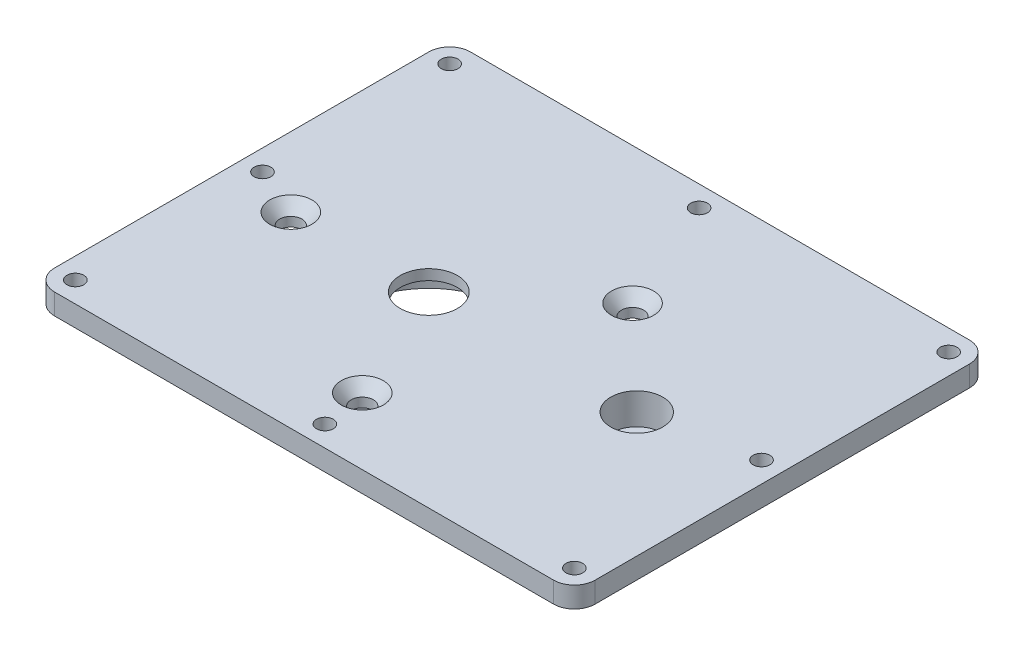
from build123d import *

# Parameters (mm, degrees)
SKETCH1_W                                        = 165.1
SKETCH1_H                                        = 127
SKETCH1_R                                        = 7.14375
SKETCH1_R_2                                      = 7.9375
BOSS_EXTRUDE1_DEPTH                              = 6.35
SKETCH2_R                                        = 28.575
SKETCH2_R_2                                      = 7.14375
SKETCH2_R_3                                      = 12.7
SKETCH2_R_4                                      = 7.9375
BOSS_EXTRUDE2_DEPTH                              = 15.875
SKETCH3_R                                        = 8.73125
CUT_EXTRUDE1_DEPTH                               = 3.175
SKETCH4_R                                        = 23.8125
CUT_EXTRUDE2_DEPTH                               = 12.7
BOSS_EXTRUDE4_START                              = 3.175
SKETCH5_R                                        = 7.9375
BOSS_EXTRUDE4_DEPTH                              = 6.35
CSK_FOR_1_4_FLAT_HEAD_MACHINE_SCREW1_D           = 6.7564
CSK_FOR_1_4_FLAT_HEAD_MACHINE_SCREW1_CSINK_D     = 12.8778
CSK_FOR_1_4_FLAT_HEAD_MACHINE_SCREW1_CSINK_ANGLE = 82
FILLET1_R                                        = 6.35
F_10_CLEARANCE_HOLE1_D                           = 5.1054


with BuildPart() as part:
    # Sketch1 → Boss-Extrude1 (new body)
    with BuildSketch(Plane(origin=(0, 0, 0), x_dir=(1, 0, 0), z_dir=(0, 1, 0))):
        Rectangle(SKETCH1_W, SKETCH1_H)
        with Locations((-19.05, -6.35)):
            Circle(SKETCH1_R, mode=Mode.SUBTRACT)
        with Locations((44.45, -6.35)):
            Circle(SKETCH1_R_2, mode=Mode.SUBTRACT)
    extrude(amount=BOSS_EXTRUDE1_DEPTH)

    # Sketch2 → Boss-Extrude2 (add)
    with BuildSketch(Plane(origin=(0, 6.35, 0), x_dir=(1, 0, 0), z_dir=(0, 1, 0))):
        with Locations((-19.05, -6.35)):
            Circle(SKETCH2_R)
        with Locations((-19.05, -6.35)):
            Circle(SKETCH2_R_2, mode=Mode.SUBTRACT)
        with Locations((44.45, -6.35)):
            Circle(SKETCH2_R_3)
        with Locations((44.45, -6.35)):
            Circle(SKETCH2_R_4, mode=Mode.SUBTRACT)
    extrude(amount=-BOSS_EXTRUDE2_DEPTH)

    # Sketch3 → Cut-Extrude1 (cut)
    with BuildSketch(Plane.XZ.offset(-6.35)):
        with Locations((-19.05, 6.35)):
            Circle(SKETCH3_R)
    extrude(amount=CUT_EXTRUDE1_DEPTH, mode=Mode.SUBTRACT)

    # Sketch4 → Cut-Extrude2 (cut)
    with BuildSketch(Plane(origin=(0, -9.525, 0), x_dir=(-1, 0, 0), z_dir=(0, -1, 0))):
        with Locations((19.05, -6.35)):
            Circle(SKETCH4_R)
    extrude(amount=-CUT_EXTRUDE2_DEPTH, mode=Mode.SUBTRACT)

    # Sketch5 → Boss-Extrude4 (add)
    with BuildSketch(Plane.XZ.offset(BOSS_EXTRUDE4_START)):
        with Locations((44.45, 6.35)):
            Circle(SKETCH5_R)
    extrude(amount=BOSS_EXTRUDE4_DEPTH)

    # CSK for 1/4 Flat Head Machine Screw1 (through all)
    with Locations(Plane(origin=(0, 6.35, 0), x_dir=(1, 0, 0), z_dir=(0, 1, 0))):
        with Locations((-61.255686472, -6.291233063), (15.015571308, 21.800289443), (-2.54, -43.18)):
            CounterSinkHole(CSK_FOR_1_4_FLAT_HEAD_MACHINE_SCREW1_D / 2, CSK_FOR_1_4_FLAT_HEAD_MACHINE_SCREW1_CSINK_D / 2, counter_sink_angle=CSK_FOR_1_4_FLAT_HEAD_MACHINE_SCREW1_CSINK_ANGLE)

    # Fillet1
    fillet1_edges = [part.edges().sort_by_distance(p)[0] for p in [
        (-82.55, 3.175, -63.5),
        (82.55, 3.175, -63.5),
        (82.55, 3.175, 63.5),
        (-82.55, 3.175, 63.5),
    ]]
    fillet(fillet1_edges, radius=FILLET1_R)

    # #10 Clearance Hole1 (through all)
    with Locations(Plane(origin=(0, 6.35, 0), x_dir=(1, 0, 0), z_dir=(0, 1, 0))):
        with Locations((-76.2, -57.15), (-76.2, 57.15), (76.2, 57.15), (76.2, -57.15), (0, 57.15), (0, -57.15), (-76.2, 0), (76.2, 0)):
            Hole(F_10_CLEARANCE_HOLE1_D / 2)


solid = part.part
